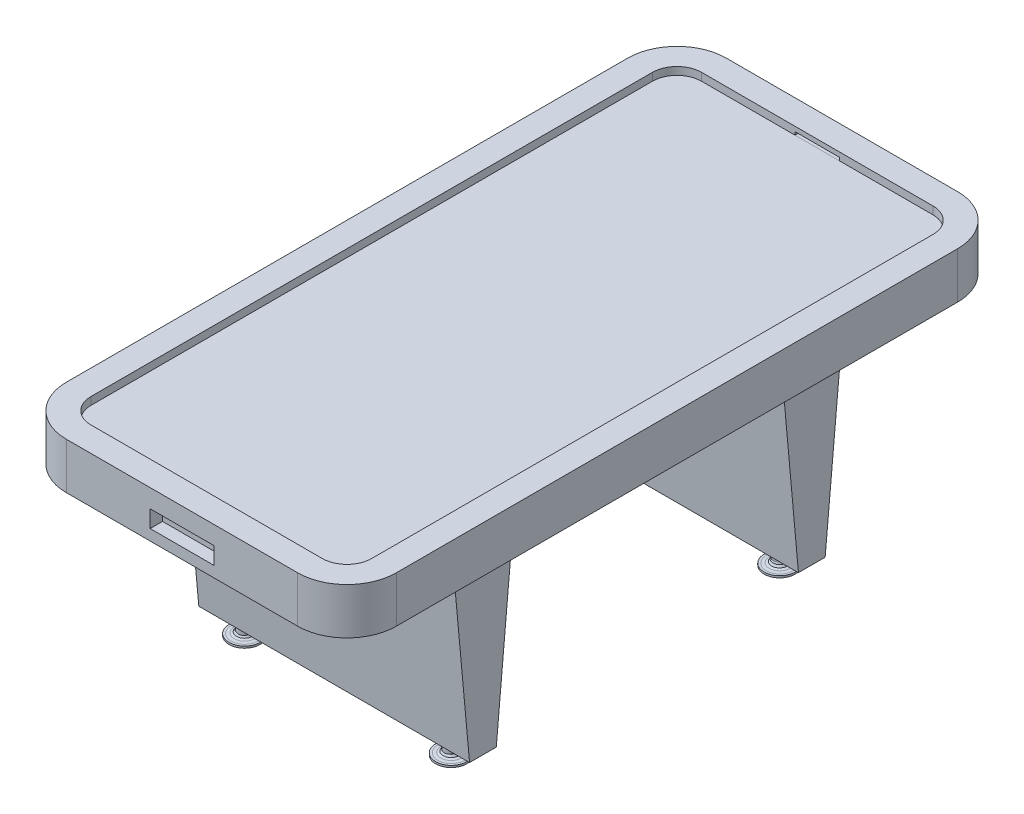
from build123d import *

# Parameters (mm, degrees)
BOSS_EXTRUDE1_DEPTH  = 150
SKETCH3_W            = 943.281144354
SKETCH3_H            = 2008.356165054
BOSS_EXTRUDE2_DEPTH  = 125
SKETCH4_W            = 877.751971552
SKETCH4_H            = 195.909630412
BOSS_EXTRUDE3_DEPTH  = 670
CUT_EXTRUDE1_DEPTH   = 1095
SKETCH6_R            = 20.377587803
BOSS_EXTRUDE4_DEPTH  = 40
SKETCH7_W            = 40.755175605
SKETCH7_H            = 40.755175605
CUT_EXTRUDE2_DEPTH   = 10
LPATTERN1_COUNT      = 2
LPATTERN1_PITCH      = 670
LPATTERN1_COUNT_DIR2 = 2
LPATTERN1_PITCH_DIR2 = 1065
SKETCH9_W            = 206.090065038
SKETCH9_H            = 55.535964875
CUT_EXTRUDE3_DEPTH   = 40
SKETCH10_W           = 145.11063413
SKETCH10_H           = 10
CUT_EXTRUDE4_DEPTH   = 40


with BuildPart() as part:
    # Sketch1 → Boss-Extrude1 (new body)
    with BuildSketch(Plane(origin=(0, 0, 0), x_dir=(1, 0, 0), z_dir=(0, 1, 0))):
        with BuildLine():
            Line((-535, 910), (-535, -910))
            ThreePointArc((-535, -910), (-488.13708499, -1023.13708499), (-375, -1070))
            Line((-375, -1070), (375, -1070))
            ThreePointArc((375, -1070), (488.13708499, -1023.13708499), (535, -910))
            Line((535, -910), (535, 910))
            ThreePointArc((535, 910), (488.13708499, 1023.13708499), (375, 1070))
            Line((375, 1070), (-375, 1070))
            ThreePointArc((-375, 1070), (-488.13708499, 1023.13708499), (-535, 910))
        make_face()
        with BuildLine():
            Line((-375, 990), (375, 990))
            ThreePointArc((375, 990), (431.568542495, 966.568542495), (455, 910))
            Line((455, 910), (455, -910))
            ThreePointArc((455, -910), (431.568542495, -966.568542495), (375, -990))
            Line((375, -990), (-375, -990))
            ThreePointArc((-375, -990), (-431.568542495, -966.568542495), (-455, -910))
            Line((-455, -910), (-455, 910))
            ThreePointArc((-455, 910), (-431.568542495, 966.568542495), (-375, 990))
        make_face(mode=Mode.SUBTRACT)
    extrude(amount=BOSS_EXTRUDE1_DEPTH)

    # Sketch3 → Boss-Extrude2 (add)
    with BuildSketch(Plane.XZ):
        Rectangle(SKETCH3_W, SKETCH3_H)
    extrude(amount=-BOSS_EXTRUDE2_DEPTH)

    # Sketch4 → Boss-Extrude3 (add)
    with BuildSketch(Plane.XZ):
        with Locations((0, 533.469606343)):
            Rectangle(SKETCH4_W, SKETCH4_H)
        with Locations((0, -533.469606343)):
            Rectangle(SKETCH4_W, SKETCH4_H)
    extrude(amount=BOSS_EXTRUDE3_DEPTH)

    # Sketch5 → Cut-Extrude1 (cut)
    with BuildSketch(Plane(origin=(438.875985776, 0, 0), x_dir=(0, 0, -1), z_dir=(1, 0, 0))):
        Polygon((-576.492082972, -597.71526573), (-631.424421549, 0), (-813.99135503, -798.682277913), (-322.424833628, -798.682277913), (-435.514791137, 0), (-489.780888803, -597.71526573), align=None)
        Polygon((435.514791137, 0), (489.780888803, -597.71526573), (576.492082972, -597.71526573), (631.424421549, 0), (813.99135503, -798.682277913), (322.424833628, -798.682277913), align=None)
    extrude(amount=-CUT_EXTRUDE1_DEPTH, mode=Mode.SUBTRACT)

    # Sketch6 → Boss-Extrude4 (add)
    with BuildSketch(Plane.XZ.offset(597.71526573)):
        with Locations((334.358840028, -533.469606343)):
            Circle(SKETCH6_R)
        with Locations((-334.358840028, -533.469606343)):
            Circle(SKETCH6_R)
        with Locations((-334.358840028, 533.469606343)):
            Circle(SKETCH6_R)
        with Locations((334.358840028, 533.469606343)):
            Circle(SKETCH6_R)
    extrude(amount=BOSS_EXTRUDE4_DEPTH)

    # Sketch7 → Cut-Extrude2 (cut)
    with BuildSketch(Plane.XZ.offset(637.71526573)):
        with Locations((354.736427831, -533.469606343)):
            Rectangle(SKETCH7_W, SKETCH7_H)
    extrude(amount=-CUT_EXTRUDE2_DEPTH, mode=Mode.SUBTRACT)

    # Sketch8 → Revolve1 (revolve)
    with BuildSketch(Plane(origin=(334.358840028, 0, 0), x_dir=(0, 0, -1), z_dir=(1, 0, 0))):
        Polygon((513.09201854, -627.71526573), (511.526412773, -633.680135283), (507.420377104, -640.04449057), (500.234814684, -643.226668213), (490.175027295, -644.86908248), (483.194766658, -644.86908248), (483.194766658, -651.028135984), (533.469606343, -651.028135984), (533.469606343, -627.71526573), align=None)
    revolve1 = revolve(axis=Axis((334.358840028, -651.028135984, -533.469606343), (0, 1, 0)))

    # LPattern1: Revolve1 2 × 2
    with Locations(*[(-i * LPATTERN1_PITCH, 0, j * LPATTERN1_PITCH_DIR2) for i in range(LPATTERN1_COUNT) for j in range(LPATTERN1_COUNT_DIR2) if (i, j) != (0, 0)]):
        add(revolve1)

    # Sketch9 → Cut-Extrude3 (cut)
    with BuildSketch(Plane.XY.offset(1070)):
        with Locations((0, 62.871676898)):
            Rectangle(SKETCH9_W, SKETCH9_H)
    cut_extrude3 = extrude(amount=-CUT_EXTRUDE3_DEPTH, mode=Mode.SUBTRACT)

    # Sketch10 → Cut-Extrude4 (cut)
    with BuildSketch(Plane(origin=(0, 0, 990), x_dir=(-1, 0, 0), z_dir=(0, 0, -1))):
        with Locations((0, 129.886472927)):
            Rectangle(SKETCH10_W, SKETCH10_H)
    cut_extrude4 = extrude(amount=-CUT_EXTRUDE4_DEPTH, mode=Mode.SUBTRACT)

    # Mirror1: Cut-Extrude3, Cut-Extrude4 across plane
    add(cut_extrude3.mirror(Plane.XY), mode=Mode.SUBTRACT)
    add(cut_extrude4.mirror(Plane.XY), mode=Mode.SUBTRACT)


solid = part.part
